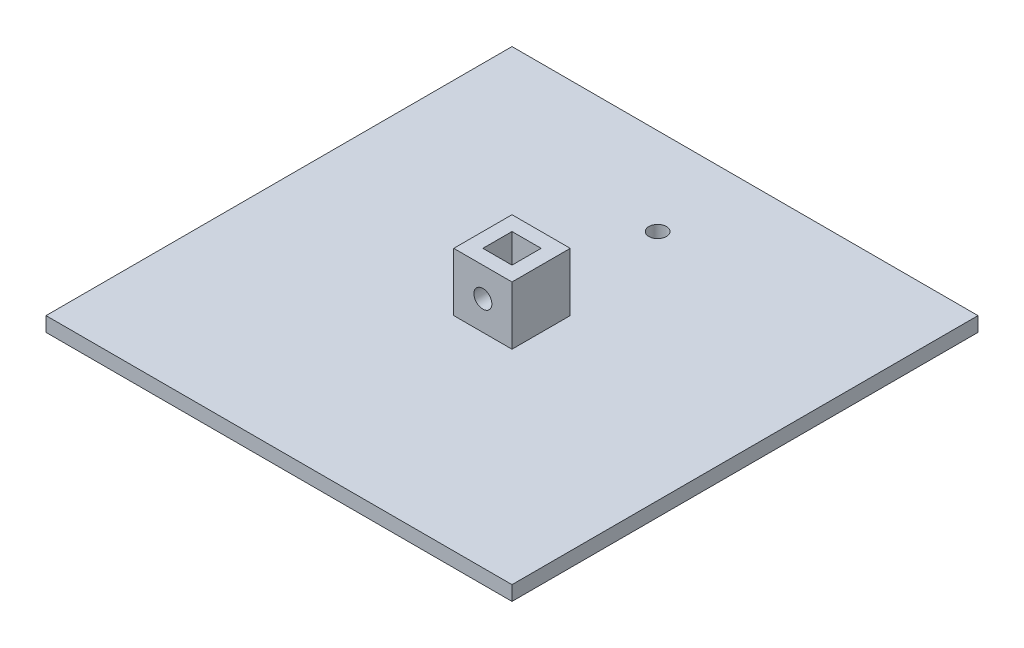
from build123d import *

# Parameters (mm, degrees)
SKETCH1_W           = 203.2
SKETCH1_H           = 203.2
BOSS_EXTRUDE1_DEPTH = 6.35
SKETCH2_W           = 25.4
SKETCH2_H           = 25.4
SKETCH2_W_2         = 12.7
SKETCH2_H_2         = 12.7
BOSS_EXTRUDE2_DEPTH = 31.75
SKETCH3_R           = 3.906287384
CUT_EXTRUDE1_DEPTH  = 25.4
SKETCH4_R           = 3.81
CUT_EXTRUDE2_DEPTH  = 25.4


with BuildPart() as part:
    # Sketch1 → Boss-Extrude1 (new body)
    with BuildSketch(Plane(origin=(0, 0, 0), x_dir=(1, 0, 0), z_dir=(0, 1, 0))):
        Rectangle(SKETCH1_W, SKETCH1_H)
    extrude(amount=BOSS_EXTRUDE1_DEPTH)

    # Sketch2 → Boss-Extrude2 (add)
    with BuildSketch(Plane(origin=(0, 0, 0), x_dir=(1, 0, 0), z_dir=(0, 1, 0))):
        Rectangle(SKETCH2_W, SKETCH2_H)
        Rectangle(SKETCH2_W_2, SKETCH2_H_2, mode=Mode.SUBTRACT)
    extrude(amount=BOSS_EXTRUDE2_DEPTH)

    # Sketch3 → Cut-Extrude1 (cut)
    with BuildSketch(Plane.XY.offset(12.7)):
        with Locations((0, 19.05)):
            Circle(SKETCH3_R)
    extrude(amount=-CUT_EXTRUDE1_DEPTH, mode=Mode.SUBTRACT)

    # Sketch4 → Cut-Extrude2 (cut)
    with BuildSketch(Plane(origin=(0, 6.35, 0), x_dir=(1, 0, 0), z_dir=(0, 1, 0))):
        with Locations((0, 63.5)):
            Circle(SKETCH4_R)
    extrude(amount=-CUT_EXTRUDE2_DEPTH, mode=Mode.SUBTRACT)


solid = part.part
